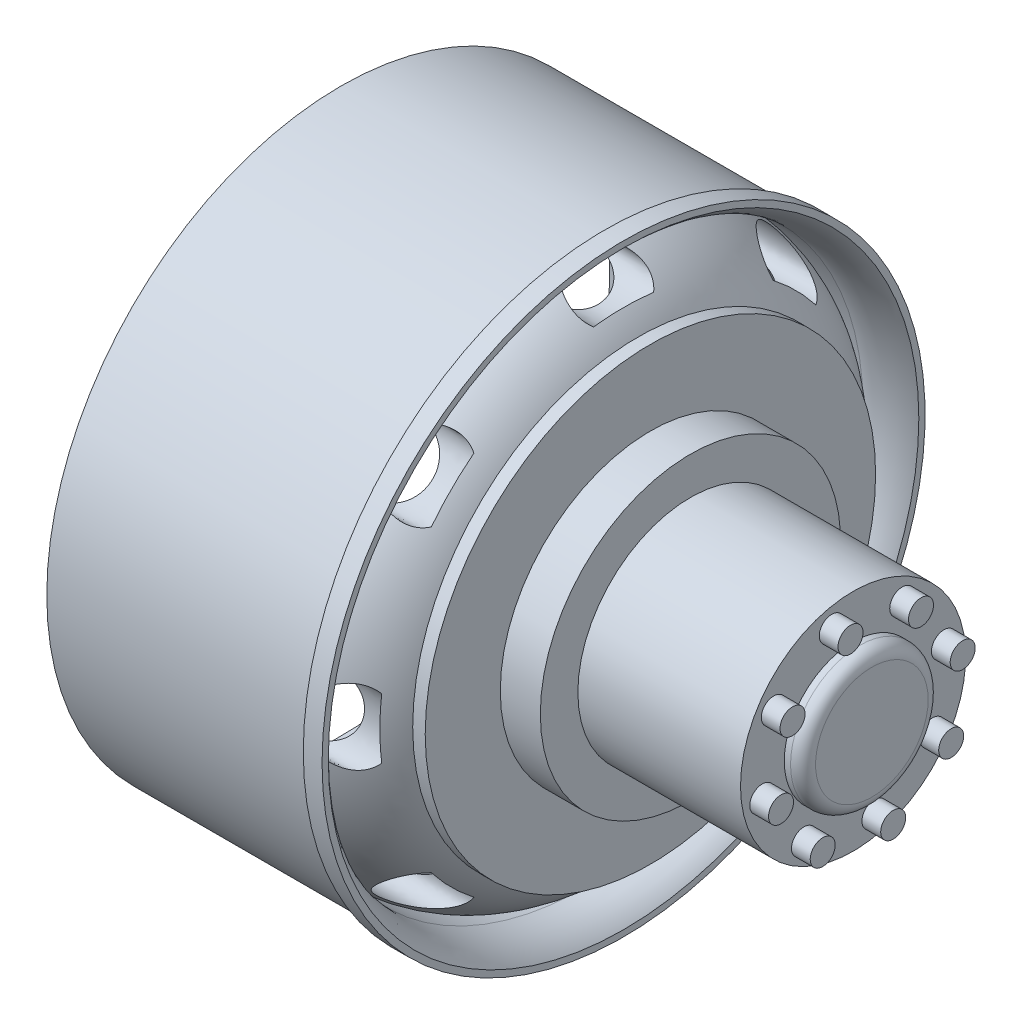
from build123d import *

# Parameters (mm, degrees)
SKETCH3_RX          = 3
SKETCH3_RY          = 1.666666667
CUT_EXTRUDE2_DEPTH  = 8.793413
CIRPATTERN1_COUNT   = 8
SKETCH4_R           = 1
SKETCH4_R_2         = 5.5
BOSS_EXTRUDE1_DEPTH = 1.5
FILLET1_R           = 1


with BuildPart() as part:
    # Sketch1 → Revolve1 (revolve)
    with BuildSketch(Plane.XY):
        with BuildLine():
            Line((-10, 23.5), (11.1, 23.5))
            Line((11.1, 23.5), (11.1, 24.1))
            Line((11.1, 24.1), (12.6, 24.1))
            Line((12.6, 24.1), (12.6, 23.6))
            ThreePointArc((12.6, 23.6), (11.157412974, 22.597075431), (9.425748686, 22.3))
            Line((9.425748686, 22.3), (6, 22.3))
            ThreePointArc((6, 22.3), (10.429661133, 21.152912389), (13.745811191, 18))
            Line((13.745811191, 18), (14.745811191, 18))
            Line((14.745811191, 18), (14.745811191, 12))
            Line((14.745811191, 12), (17.945811191, 12))
            Line((17.945811191, 12), (17.945811191, 9))
            Line((17.945811191, 9), (18.945811191, 9))
            Line((18.945811191, 9), (30.945811191, 9))
            Line((30.945811191, 9), (30.945811191, 0))
            Line((30.945811191, 0), (12.541986778, 0))
            Line((12.541986778, 0), (12.541986778, 8.483712034))
            Line((12.541986778, 8.483712034), (12.541986778, 16))
            ThreePointArc((12.541986778, 16), (9.914319577, 19.128751492), (6, 20.3))
            Line((6, 20.3), (3.806587083, 20.3))
            Line((3.806587083, 20.3), (3.806587083, 21.5))
            Line((3.806587083, 21.5), (-10, 21.5))
            Line((-10, 21.5), (-10, 23.5))
        make_face()
    revolve(axis=Axis((-25, 0, 0), (1, 0, 0)))

    # Sketch3 → Cut-Extrude2 (cut)
    with BuildSketch(Plane(origin=(12.6, 0, 0), x_dir=(0, 0, -1), z_dir=(1, 0, 0))):
        with Locations((0, 20.323082194)):
            Ellipse(SKETCH3_RX, SKETCH3_RY)
    cut_extrude2 = extrude(amount=-CUT_EXTRUDE2_DEPTH, mode=Mode.SUBTRACT)

    # CirPattern1: Cut-Extrude2 ×8 about axis
    cirpattern1_axis = Axis((0, 0, 0), (-1, 0, 0))
    for i in range(1, CIRPATTERN1_COUNT):
        add(cut_extrude2.rotate(cirpattern1_axis, i * 360 / CIRPATTERN1_COUNT), mode=Mode.SUBTRACT)

    # Sketch4 → Boss-Extrude1 (add)
    with BuildSketch(Plane(origin=(30.945811191, 0, 0), x_dir=(0, 0, -1), z_dir=(1, 0, 0))):
        with Locations((-1.705783559, 7.260002429)):
            Circle(SKETCH4_R)
        with Locations((3.927425827, 6.339768071)):
            Circle(SKETCH4_R)
        with Locations((7.260002429, 1.705783559)):
            Circle(SKETCH4_R)
        with Locations((6.339768071, -3.927425827)):
            Circle(SKETCH4_R)
        with Locations((1.705783559, -7.260002429)):
            Circle(SKETCH4_R)
        with Locations((-3.927425827, -6.339768071)):
            Circle(SKETCH4_R)
        with Locations((-7.260002429, -1.705783559)):
            Circle(SKETCH4_R)
        with Locations((-6.339768071, 3.927425827)):
            Circle(SKETCH4_R)
        Circle(SKETCH4_R_2)
    extrude(amount=BOSS_EXTRUDE1_DEPTH)

    # Fillet1
    fillet1_edges = [part.edges().sort_by_distance(p)[0] for p in [
        (32.445811191, 0, 5.5),
    ]]
    fillet(fillet1_edges, radius=FILLET1_R)


solid = part.part
